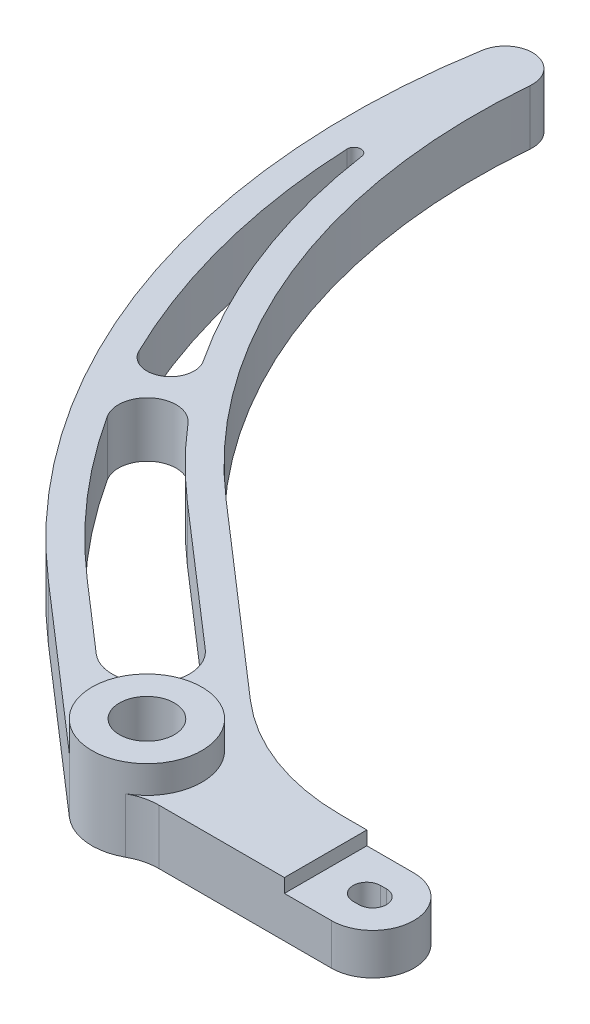
from build123d import *

# Parameters (mm, degrees)
SKETCH1_R           = 6.35
BOSS_EXTRUDE1_DEPTH = 12.7
CUT_EXTRUDE2_DEPTH  = 13.7
FILLET1_R           = 12.7
SKETCH4_R           = 12.7
SKETCH4_R_2         = 6.35
BOSS_EXTRUDE2_DEPTH = 6.35
SKETCH2_W           = 27.073872012
SKETCH2_H           = 29.596885175
CUT_EXTRUDE1_DEPTH  = 3.175


with BuildPart() as part:
    # Sketch1 → Boss-Extrude1 (new body)
    with BuildSketch(Plane(origin=(0, 0, 0), x_dir=(1, 0, 0), z_dir=(0, 1, 0))):
        with BuildLine():
            Line((1.339902706, -174.625), (-42.399739587, -174.625))
            ThreePointArc((-42.399739587, -174.625), (-50.754602331, -177.79991886), (-59.131949668, -174.684811669))
            Line((-59.131949668, -174.684811669), (-96.253765638, -142.415309363))
            ThreePointArc((-96.253765638, -142.415309363), (-144.617963608, -71.634466036), (-152.13989844, 13.761341376))
            ThreePointArc((-152.13989844, 13.761341376), (-145.072520944, 18.99854995), (-139.553151074, 12.149262793))
            ThreePointArc((-139.553151074, 12.149262793), (-129.869632709, -52.503000495), (-91.90140484, -105.720472707))
            Line((-91.90140484, -105.720472707), (-48.88478864, -143.114246675))
            ThreePointArc((-48.88478864, -143.114246675), (-33.347524936, -152.357947214), (-15.556989968, -155.575))
            Line((-15.556989968, -155.575), (1.339902706, -155.575))
            ThreePointArc((1.339902706, -155.575), (10.864902706, -165.1), (1.339902706, -174.625))
        make_face()
        with Locations((-50.8, -165.1)):
            Circle(SKETCH1_R, mode=Mode.SUBTRACT)
        with BuildLine():
            Line((0, -161.925), (1.339902706, -161.925))
            ThreePointArc((1.339902706, -161.925), (4.514902706, -165.1), (1.339902706, -168.275))
            Line((1.339902706, -168.275), (0, -168.275))
            ThreePointArc((0, -168.275), (-3.175, -165.1), (0, -161.925))
        make_face(mode=Mode.SUBTRACT)
    extrude(amount=BOSS_EXTRUDE1_DEPTH)

    # Sketch3 → Cut-Extrude2 (cut, through all)
    with BuildSketch(Plane(origin=(0, 12.7, 0), x_dir=(1, 0, 0), z_dir=(0, 1, 0))):
        with BuildLine():
            Line((-64.278893585, -138.146187914), (-96.067379674, -110.512878542))
            ThreePointArc((-96.067379674, -110.512878542), (-104.093661598, -102.988093371), (-111.532318829, -94.88192461))
            ThreePointArc((-111.532318829, -94.88192461), (-120.588765116, -93.847414192), (-122.222718656, -102.815113283))
            ThreePointArc((-122.222718656, -102.815113283), (-108.389889378, -121.287896312), (-92.087790804, -137.622903528))
            Line((-92.087790804, -137.622903528), (-75.989121055, -151.617263638))
            ThreePointArc((-75.989121055, -151.617263638), (-63.398469458, -150.736839511), (-64.278893585, -138.146187914))
        make_face()
        with BuildLine():
            ThreePointArc((-122.168303836, -80.727586976), (-124.013598755, -88.474110491), (-131.62448434, -86.131428157))
            ThreePointArc((-131.62448434, -86.131428157), (-143.140144863, -54.755391727), (-148.016867664, -21.690551276))
            ThreePointArc((-148.016867664, -21.690551276), (-146.581764091, -20.040770563), (-144.860415421, -21.389198324))
            ThreePointArc((-144.860415421, -21.389198324), (-136.771142128, -52.303847297), (-122.168303836, -80.727586976))
        make_face()
    extrude(amount=-CUT_EXTRUDE2_DEPTH, mode=Mode.SUBTRACT)

    # Fillet1
    fillet1_edges = [part.edges().sort_by_distance(p)[0] for p in [
        (-42.399739587, 6.35, 174.625),
    ]]
    fillet(fillet1_edges, radius=FILLET1_R)

    # Sketch4 → Boss-Extrude2 (add)
    with BuildSketch(Plane(origin=(0, 12.7, 0), x_dir=(1, 0, 0), z_dir=(0, 1, 0))):
        with Locations((-50.8, -165.1)):
            Circle(SKETCH4_R)
        with Locations((-50.8, -165.1)):
            Circle(SKETCH4_R_2, mode=Mode.SUBTRACT)
    extrude(amount=BOSS_EXTRUDE2_DEPTH)

    # Sketch2 → Cut-Extrude1 (cut)
    with BuildSketch(Plane(origin=(0, 12.7, 0), x_dir=(1, 0, 0), z_dir=(0, 1, 0))):
        with Locations((4.011936006, -165.256904056)):
            Rectangle(SKETCH2_W, SKETCH2_H)
    extrude(amount=-CUT_EXTRUDE1_DEPTH, mode=Mode.SUBTRACT)


solid = part.part
